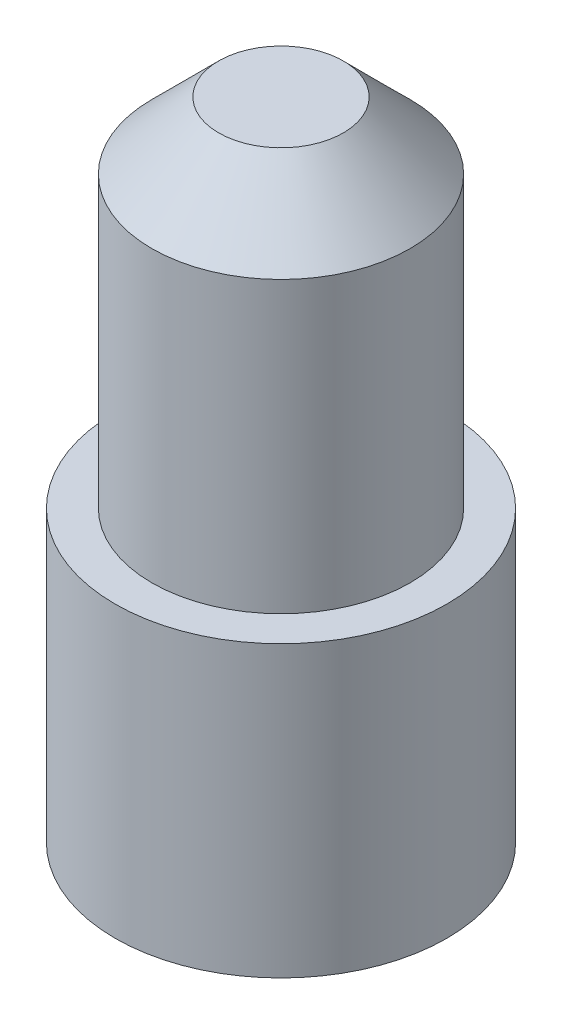
from build123d import *


with BuildPart() as part:
    # Sketch1 one side → Revolve2 (revolve)
    with BuildSketch(Plane.XY):
        Polygon((0, -1.125), (0, -15.625), (3.725, -15.625), (3.725, -9.125), (2.9, -9.125), (2.9, -2.625), (1.4, -1.125), align=None)
    revolve(axis=Axis((0, 19.958333333, 0), (0, -1, 0)))


solid = part.part
